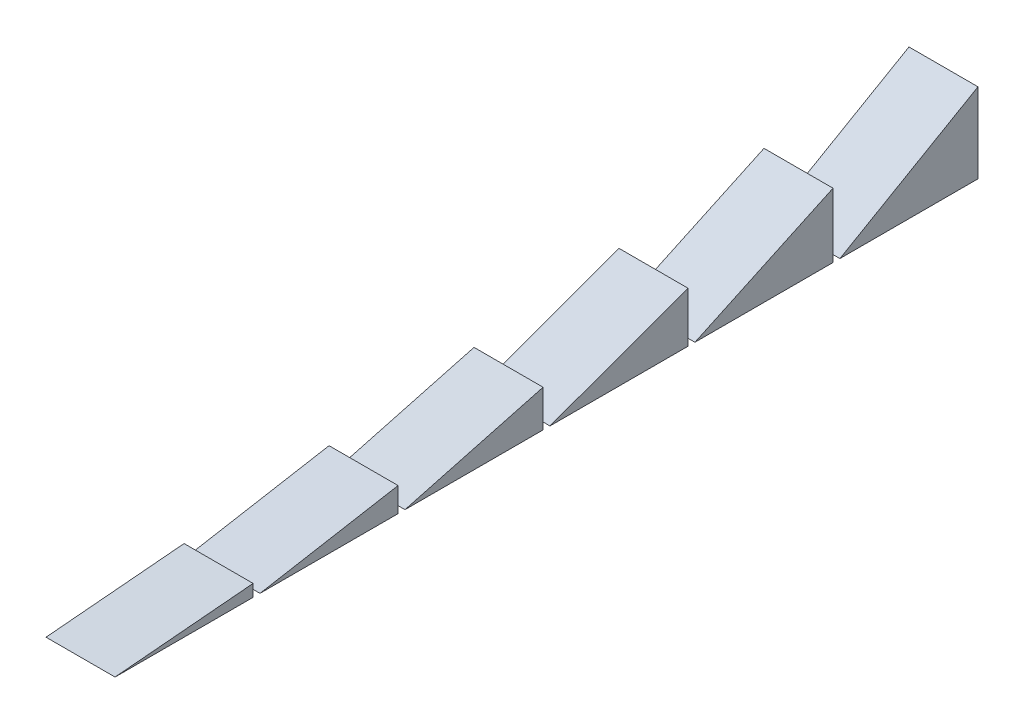
from build123d import *

# Parameters (mm, degrees)
BOSS_EXTRUDE1_DEPTH   = 25.4
BOSS_EXTRUDE1_2_DEPTH = 25.4
BOSS_EXTRUDE1_3_DEPTH = 25.4
BOSS_EXTRUDE1_4_DEPTH = 25.4
BOSS_EXTRUDE1_5_DEPTH = 25.4
BOSS_EXTRUDE1_6_DEPTH = 25.4


with BuildPart() as part:
    # Sketch1 → Boss-Extrude1 (new body)
    with BuildSketch(Plane(origin=(0, 0, 0), x_dir=(0, 0, -1), z_dir=(1, 0, 0))):
        Polygon((0, 0), (50.8, 0), (50.8, 4.444424107), align=None)
    extrude(amount=BOSS_EXTRUDE1_DEPTH)


with BuildPart() as body_2:
    # Sketch1 → Boss-Extrude1 2 (new body)
    with BuildSketch(Plane(origin=(0, 0, 0), x_dir=(0, 0, -1), z_dir=(1, 0, 0))):
        Polygon((53.34, 0), (104.14, 0), (104.14, 8.95741062), align=None)
    extrude(amount=BOSS_EXTRUDE1_2_DEPTH)


with BuildPart() as body_3:
    # Sketch1 → Boss-Extrude1 3 (new body)
    with BuildSketch(Plane(origin=(0, 0, 0), x_dir=(0, 0, -1), z_dir=(1, 0, 0))):
        Polygon((106.68, 0), (157.48, 0), (157.48, 13.611818976), align=None)
    extrude(amount=BOSS_EXTRUDE1_3_DEPTH)


with BuildPart() as body_4:
    # Sketch1 → Boss-Extrude1 4 (new body)
    with BuildSketch(Plane(origin=(0, 0, 0), x_dir=(0, 0, -1), z_dir=(1, 0, 0))):
        Polygon((160.02, 0), (210.82, 0), (210.82, 18.489687901), align=None)
    extrude(amount=BOSS_EXTRUDE1_4_DEPTH)


with BuildPart() as body_5:
    # Sketch1 → Boss-Extrude1 5 (new body)
    with BuildSketch(Plane(origin=(0, 0, 0), x_dir=(0, 0, -1), z_dir=(1, 0, 0))):
        Polygon((213.36, 0), (264.16, 0), (264.16, 23.688429034), align=None)
    extrude(amount=BOSS_EXTRUDE1_5_DEPTH)


with BuildPart() as body_6:
    # Sketch1 → Boss-Extrude1 6 (new body)
    with BuildSketch(Plane(origin=(0, 0, 0), x_dir=(0, 0, -1), z_dir=(1, 0, 0))):
        Polygon((266.7, 0), (317.5, 0), (317.5, 29.329393675), align=None)
    extrude(amount=BOSS_EXTRUDE1_6_DEPTH)


solid = Compound([part.part, body_2.part, body_3.part, body_4.part, body_5.part, body_6.part])
